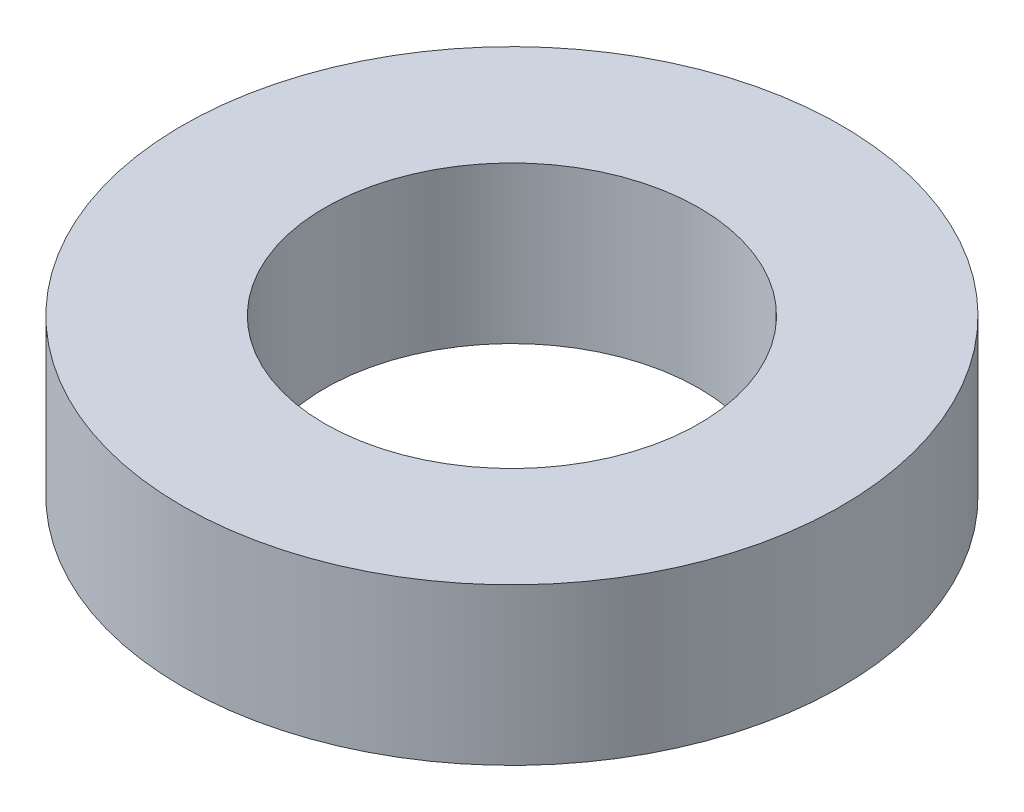
from build123d import *

# Parameters (mm, degrees)
SKETCH1_R           = 14.986
SKETCH1_R_2         = 8.509
BOSS_EXTRUDE1_DEPTH = 7.112


with BuildPart() as part:
    # Sketch1 → Boss-Extrude1 (new body)
    with BuildSketch(Plane(origin=(0, 0, 0), x_dir=(1, 0, 0), z_dir=(0, 1, 0))):
        Circle(SKETCH1_R)
        Circle(SKETCH1_R_2, mode=Mode.SUBTRACT)
    extrude(amount=BOSS_EXTRUDE1_DEPTH)


solid = part.part
